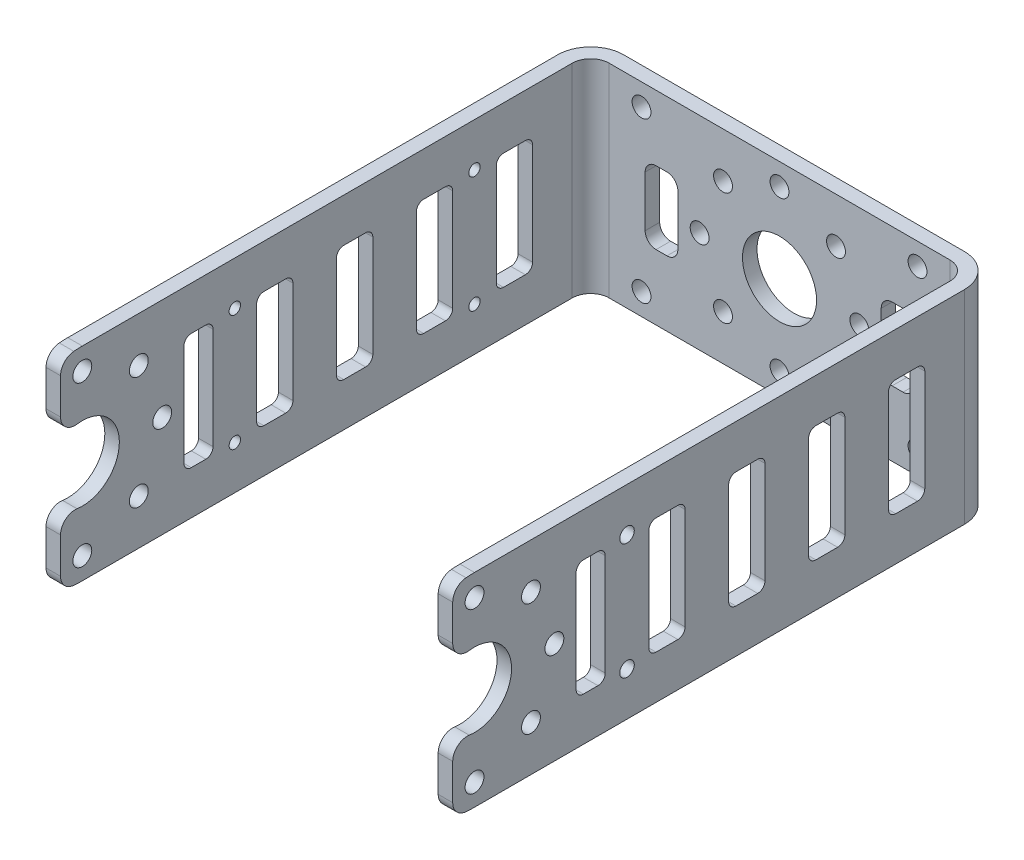
from build123d import *

# Parameters (mm, degrees)
BOSS_EXTRUDE1_DEPTH              = 54
SKETCH2_W                        = 54
SKETCH2_H                        = 28
BOSS_EXTRUDE2_DEPTH              = 72
CUT_EXTRUDE1_START               = -52
CUT_EXTRUDE1_DEPTH               = 52
SKETCH4_W                        = 52
SKETCH4_H                        = 28
CUT_EXTRUDE2_DEPTH               = 70
BOSS_EXTRUDE3_DEPTH              = 2
SKETCH6_W                        = 5
SKETCH6_H                        = 16
CUT_EXTRUDE3_DEPTH               = 97.566039579
SKETCH7_W                        = 5
SKETCH7_H                        = 16
CUT_EXTRUDE4_DEPTH               = 97.566039579
SKETCH8_W                        = 5
SKETCH8_H                        = 16
CUT_EXTRUDE5_DEPTH               = 97.566039579
SKETCH9_W                        = 4
SKETCH9_H                        = 16
CUT_EXTRUDE6_DEPTH               = 97.566039579
SKETCH10_W                       = 4.5
SKETCH10_H                       = 10
CUT_EXTRUDE7_DEPTH               = 96.021050299
SKETCH11_W                       = 4
SKETCH11_H                       = 16
CUT_EXTRUDE8_DEPTH               = 97.566039579
SKETCH12_W                       = 5
SKETCH12_H                       = 16
CUT_EXTRUDE9_DEPTH               = 97.566039579
SKETCH13_W                       = 5
SKETCH13_H                       = 16
CUT_EXTRUDE10_DEPTH              = 97.566039579
SKETCH14_W                       = 5
SKETCH14_H                       = 16
CUT_EXTRUDE11_DEPTH              = 97.566039579
SKETCH15_W                       = 5
SKETCH15_H                       = 16
CUT_EXTRUDE12_DEPTH              = 97.566039579
SKETCH16_W                       = 4.5
SKETCH16_H                       = 10
CUT_EXTRUDE13_DEPTH              = 96.021050299
SKETCH17_W                       = 5
SKETCH17_H                       = 16
CUT_EXTRUDE14_DEPTH              = 98.698515854
F_2_0_2_DIAMETER_HOLE1_D         = 2
F_2_0_2_DIAMETER_HOLE1_DEPTH     = 2
F_2_6_2_6_DIAMETER_HOLE1_D       = 2.6
F_2_6_2_6_DIAMETER_HOLE1_DEPTH   = 2
F_10_2_10_2_DIAMETER_HOLE1_D     = 10.2
F_10_2_10_2_DIAMETER_HOLE1_DEPTH = 2
F_2_6_2_6_DIAMETER_HOLE2_D       = 2.6
HOLE1_D                          = 1.567
HOLE1_DEPTH                      = 2
F_10_2_10_2_DIAMETER_HOLE2_D     = 10.2
F_10_2_10_2_DIAMETER_HOLE3_D     = 10.2
F_2_6_2_6_DIAMETER_HOLE3_D       = 2.6
FILLET1_R                        = 1
FILLET2_R                        = 1.5
FILLET3_R                        = 2
FILLET4_R                        = 2.54
FILLET5_R                        = 4.54


with BuildPart() as part:
    # Sketch1 → Boss-Extrude1 (new body)
    with BuildSketch(Plane(origin=(-2, 0, 0), x_dir=(0, -1, 0), z_dir=(-1, 0, 0))):
        with BuildLine():
            Line((-28, 72), (0, 72))
            ThreePointArc((0, 72), (-0.081538867, 73.508787487), (-0.325205669, 75))
            Line((-0.325205669, 75), (-27.674794331, 75))
            ThreePointArc((-27.674794331, 75), (-27.918461133, 73.508787487), (-28, 72))
        make_face()
    extrude(amount=-BOSS_EXTRUDE1_DEPTH)

    # Sketch2 → Boss-Extrude2 (add)
    with BuildSketch(Plane(origin=(0, 0, 72), x_dir=(-1, 0, 0), z_dir=(0, 0, -1))):
        with Locations((-25, 14)):
            Rectangle(SKETCH2_W, SKETCH2_H)
    extrude(amount=BOSS_EXTRUDE2_DEPTH)

    # Sketch3 → Cut-Extrude1 (cut)
    with BuildSketch(Plane(origin=(52, 0, 0), x_dir=(0, 0, -1), z_dir=(1, 0, 0)).offset(CUT_EXTRUDE1_START)):
        with BuildLine():
            Line((-72, 0), (-72, 28))
            ThreePointArc((-72, 28), (-73.508787487, 27.918461133), (-75, 27.674794331))
            Line((-75, 27.674794331), (-75, 0.325205669))
            ThreePointArc((-75, 0.325205669), (-73.508787487, 0.081538867), (-72, 0))
        make_face()
    extrude(amount=CUT_EXTRUDE1_DEPTH, mode=Mode.SUBTRACT)

    # Sketch4 → Cut-Extrude2 (cut)
    with BuildSketch(Plane.XY.offset(72)):
        with Locations((26, 14)):
            Rectangle(SKETCH4_W, SKETCH4_H)
    extrude(amount=-CUT_EXTRUDE2_DEPTH, mode=Mode.SUBTRACT)

    # Sketch5 → Boss-Extrude3 (add)
    with BuildSketch(Plane(origin=(52, 0, 0), x_dir=(0, 0, -1), z_dir=(1, 0, 0))):
        with BuildLine():
            Line((-72, 28), (0, 28))
            Line((0, 28), (0, 0))
            Line((0, 0), (-72, 0))
            ThreePointArc((-72, 0), (-73.508787487, 0.081538867), (-75, 0.325205669))
            Line((-75, 0.325205669), (-75, 27.674794331))
            ThreePointArc((-75, 27.674794331), (-73.508787487, 27.918461133), (-72, 28))
        make_face()
    extrude(amount=BOSS_EXTRUDE3_DEPTH)

    # Sketch6 → Cut-Extrude3 (cut, through all)
    with BuildSketch(Plane.ZY.offset(-52)):
        with Locations((23.5, 14)):
            Rectangle(SKETCH6_W, SKETCH6_H)
    extrude(amount=-CUT_EXTRUDE3_DEPTH, mode=Mode.SUBTRACT)

    # Sketch7 → Cut-Extrude4 (cut, through all)
    with BuildSketch(Plane.ZY.offset(-52)):
        with Locations((12.5, 14)):
            Rectangle(SKETCH7_W, SKETCH7_H)
    extrude(amount=-CUT_EXTRUDE4_DEPTH, mode=Mode.SUBTRACT)

    # Sketch8 → Cut-Extrude5 (cut, through all)
    with BuildSketch(Plane.ZY.offset(-52)):
        with Locations((45.5, 14)):
            Rectangle(SKETCH8_W, SKETCH8_H)
    extrude(amount=-CUT_EXTRUDE5_DEPTH, mode=Mode.SUBTRACT)

    # Sketch9 → Cut-Extrude6 (cut, through all)
    with BuildSketch(Plane.ZY.offset(-52)):
        with Locations((56, 14)):
            Rectangle(SKETCH9_W, SKETCH9_H)
    extrude(amount=-CUT_EXTRUDE6_DEPTH, mode=Mode.SUBTRACT)

    # Sketch10 → Cut-Extrude7 (cut, through all)
    with BuildSketch(Plane.XY.offset(2)):
        with Locations((9.75, 14)):
            Rectangle(SKETCH10_W, SKETCH10_H)
    extrude(amount=-CUT_EXTRUDE7_DEPTH, mode=Mode.SUBTRACT)

    # Sketch11 → Cut-Extrude8 (cut, through all)
    with BuildSketch(Plane(origin=(0, 0, 0), x_dir=(0, 0, -1), z_dir=(1, 0, 0))):
        with Locations((-56, 14)):
            Rectangle(SKETCH11_W, SKETCH11_H)
    extrude(amount=-CUT_EXTRUDE8_DEPTH, mode=Mode.SUBTRACT)

    # Sketch12 → Cut-Extrude9 (cut, through all)
    with BuildSketch(Plane(origin=(0, 0, 0), x_dir=(0, 0, -1), z_dir=(1, 0, 0))):
        with Locations((-45.5, 14)):
            Rectangle(SKETCH12_W, SKETCH12_H)
    extrude(amount=-CUT_EXTRUDE9_DEPTH, mode=Mode.SUBTRACT)

    # Sketch13 → Cut-Extrude10 (cut, through all)
    with BuildSketch(Plane(origin=(0, 0, 0), x_dir=(0, 0, -1), z_dir=(1, 0, 0))):
        with Locations((-12.5, 14)):
            Rectangle(SKETCH13_W, SKETCH13_H)
    extrude(amount=-CUT_EXTRUDE10_DEPTH, mode=Mode.SUBTRACT)

    # Sketch14 → Cut-Extrude11 (cut, through all)
    with BuildSketch(Plane(origin=(0, 0, 0), x_dir=(0, 0, -1), z_dir=(1, 0, 0))):
        with Locations((-23.5, 14)):
            Rectangle(SKETCH14_W, SKETCH14_H)
    extrude(amount=-CUT_EXTRUDE11_DEPTH, mode=Mode.SUBTRACT)

    # Sketch15 → Cut-Extrude12 (cut, through all)
    with BuildSketch(Plane(origin=(0, 0, 0), x_dir=(0, 0, -1), z_dir=(1, 0, 0))):
        with Locations((-34.5, 14)):
            Rectangle(SKETCH15_W, SKETCH15_H)
    extrude(amount=-CUT_EXTRUDE12_DEPTH, mode=Mode.SUBTRACT)

    # Sketch16 → Cut-Extrude13 (cut, through all)
    with BuildSketch(Plane.XY.offset(2)):
        with Locations((42.25, 14)):
            Rectangle(SKETCH16_W, SKETCH16_H)
    extrude(amount=-CUT_EXTRUDE13_DEPTH, mode=Mode.SUBTRACT)

    # Sketch17 → Cut-Extrude14 (cut, through all)
    with BuildSketch(Plane(origin=(54, 0, 0), x_dir=(0, 0, -1), z_dir=(1, 0, 0))):
        with Locations((-34.5, 14)):
            Rectangle(SKETCH17_W, SKETCH17_H)
    extrude(amount=-CUT_EXTRUDE14_DEPTH, mode=Mode.SUBTRACT)

    # Ø2.0 (2) Diameter Hole1
    with Locations(Plane.ZY.offset(-52)):
        with Locations((51, 22), (51, 6)):
            Hole(F_2_0_2_DIAMETER_HOLE1_D / 2, depth=F_2_0_2_DIAMETER_HOLE1_DEPTH)

    # Ø2.6 (2.6) Diameter Hole1
    with Locations(Plane.ZY.offset(-52)):
        with Locations((72, 25), (72, 3), (64.221825407, 21.778174593), (64.221825407, 6.221825407), (61, 14)):
            Hole(F_2_6_2_6_DIAMETER_HOLE1_D / 2, depth=F_2_6_2_6_DIAMETER_HOLE1_DEPTH)

    # Ø10.2 (10.2) Diameter Hole1
    with Locations(Plane(origin=(54, 0, 0), x_dir=(0, 0, -1), z_dir=(1, 0, 0))):
        with Locations((-72, 14)):
            Hole(F_10_2_10_2_DIAMETER_HOLE1_D / 2, depth=F_10_2_10_2_DIAMETER_HOLE1_DEPTH)

    # Ø2.6 (2.6) Diameter Hole2 (through all)
    with Locations(Plane(origin=(0, 0, 0), x_dir=(0, 0, -1), z_dir=(1, 0, 0))):
        with Locations((-72, 25), (-72, 3), (-64.221825407, 21.778174593), (-64.221825407, 6.221825407), (-61, 14)):
            Hole(F_2_6_2_6_DIAMETER_HOLE2_D / 2)

    # Hole1
    with Locations(Plane(origin=(0, 0, 0), x_dir=(0, 0, -1), z_dir=(1, 0, 0))):
        with Locations((-18, 22), (-18, 6), (-51, 6), (-51, 22)):
            Hole(HOLE1_D / 2, depth=HOLE1_DEPTH)

    # Ø10.2 (10.2) Diameter Hole2 (through all)
    with Locations(Plane(origin=(0, 0, 0), x_dir=(0, 0, -1), z_dir=(1, 0, 0))):
        with Locations((-72, 14)):
            Hole(F_10_2_10_2_DIAMETER_HOLE2_D / 2)

    # Ø10.2 (10.2) Diameter Hole3 (through all)
    with Locations(Plane.XY.offset(2)):
        with Locations((26, 14)):
            Hole(F_10_2_10_2_DIAMETER_HOLE3_D / 2)

    # Ø2.6 (2.6) Diameter Hole3 (through all)
    with Locations(Plane.XY.offset(2)):
        with Locations((45, 3), (7, 3), (45, 25), (7, 25), (26, 25), (18.221825407, 21.778174593), (15, 14), (18.221825407, 6.221825407), (26, 3), (33.778174593, 6.221825407), (37, 14), (33.778174593, 21.778174593)):
            Hole(F_2_6_2_6_DIAMETER_HOLE3_D / 2)

    # Fillet1
    fillet1_edges = [part.edges().sort_by_distance(p)[0] for p in [
        (-1, 22, 48),
        (53, 22, 58),
        (53, 22, 48),
        (-1, 22, 58),
        (-1, 6, 10),
        (-1, 6, 58),
        (53, 6, 15),
        (53, 22, 32),
        (53, 22, 43),
        (53, 6, 37),
        (53, 22, 54),
        (53, 6, 21),
        (-1, 6, 48),
        (53, 6, 26),
        (-1, 22, 54),
        (53, 6, 10),
        (53, 22, 37),
        (-1, 22, 32),
        (53, 22, 21),
        (-1, 6, 37),
        (53, 22, 26),
        (-1, 6, 32),
        (53, 22, 10),
        (-1, 22, 37),
        (53, 22, 15),
        (-1, 22, 26),
        (53, 6, 48),
        (-1, 22, 21),
        (53, 6, 43),
        (-1, 6, 26),
        (53, 6, 58),
        (-1, 6, 21),
        (53, 6, 54),
        (-1, 22, 15),
        (-1, 6, 43),
        (-1, 22, 10),
        (-1, 22, 43),
        (-1, 6, 15),
        (-1, 6, 54),
        (53, 6, 32),
    ]]
    fillet(fillet1_edges, radius=FILLET1_R)

    # Fillet2
    fillet2_edges = [part.edges().sort_by_distance(p)[0] for p in [
        (7.5, 9, 1),
        (12, 19, 1),
        (40, 9, 1),
        (40, 19, 1),
        (12, 9, 1),
        (44.5, 19, 1),
        (44.5, 9, 1),
        (7.5, 19, 1),
    ]]
    fillet(fillet2_edges, radius=FILLET2_R)

    # Fillet3
    fillet3_edges = [part.edges().sort_by_distance(p)[0] for p in [
        (53, 27.674794331, 75),
        (53, 0.325205669, 75),
        (-1, 9.875681875, 75),
        (53, 9.875681875, 75),
        (53, 18.124318125, 75),
        (-1, 0.325205669, 75),
        (-1, 18.124318125, 75),
        (-1, 27.674794331, 75),
    ]]
    fillet(fillet3_edges, radius=FILLET3_R)

    # Fillet4
    fillet4_edges = [part.edges().sort_by_distance(p)[0] for p in [
        (52, 14, 2),
        (0, 14, 2),
    ]]
    fillet(fillet4_edges, radius=FILLET4_R)

    # Fillet5
    fillet5_edges = [part.edges().sort_by_distance(p)[0] for p in [
        (54, 14, 0),
        (-2, 14, 0),
    ]]
    fillet(fillet5_edges, radius=FILLET5_R)


solid = part.part
